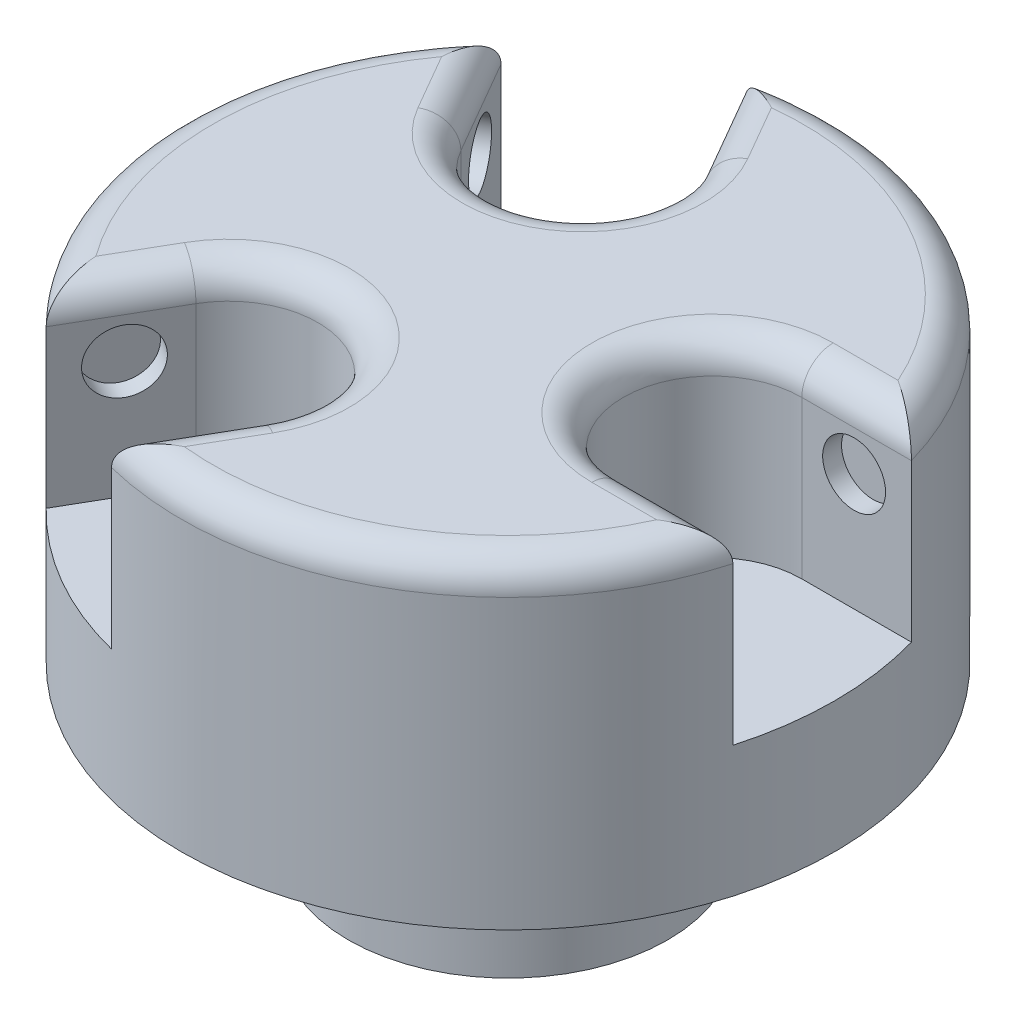
from build123d import *

# Parameters (mm, degrees)
SKETCH1_R                   = 51.94
BOSS_EXTRUDE1_DEPTH         = 50.8
CUT_EXTRUDE1_START          = -30
CUT_EXTRUDE1_DEPTH          = 120.309390324
SKETCH3_R                   = 5
CUT_EXTRUDE2_DEPTH          = 3
CIRPATTERN1_COUNT           = 3
CIRPATTERN1_COPY_1_SKETCH_R = 5
CIRPATTERN1_COPY_1_DEPTH    = 3
CIRPATTERN1_COPY_2_SKETCH_R = 5
CIRPATTERN1_COPY_2_DEPTH    = 3
FILLET2_R                   = 5
SKETCH6_R                   = 25.4
BOSS_EXTRUDE2_DEPTH         = 25.4


with BuildPart() as part:
    # Sketch1 → Boss-Extrude1 (new body)
    with BuildSketch(Plane(origin=(0, 0, 0), x_dir=(1, 0, 0), z_dir=(0, 1, 0))):
        Circle(SKETCH1_R)
    extrude(amount=BOSS_EXTRUDE1_DEPTH)

    # Sketch2 → Cut-Extrude1 (cut)
    with BuildSketch(Plane(origin=(0, 50.8, 0), x_dir=(1, 0, 0), z_dir=(0, 1, 0)).offset(CUT_EXTRUDE1_START)):
        with BuildLine():
            Line((302.928702249, 14.198513891), (49.96164332, 14.198513891))
            Line((49.96164332, 14.198513891), (32.527604999, 14.198513891))
            ThreePointArc((32.527604999, 14.198513891), (18.329091108, 0), (32.527604999, -14.198513891))
            Line((32.527604999, -14.198513891), (49.96164332, -14.198513891))
            Line((49.96164332, -14.198513891), (302.928702249, -14.198513891))
            Line((302.928702249, -14.198513891), (808.862820107, -14.198513891))
            Line((808.862820107, -14.198513891), (808.862820107, 14.198513891))
            Line((808.862820107, 14.198513891), (302.928702249, 14.198513891))
        make_face()
    cut_extrude1 = extrude(amount=CUT_EXTRUDE1_DEPTH, mode=Mode.SUBTRACT)

    # Sketch3 → Cut-Extrude2 (cut)
    with BuildSketch(Plane.XY.offset(-14.198513891)):
        with Locations((40.848803203, 39.398991639)):
            Circle(SKETCH3_R)
    cut_extrude2 = extrude(amount=-CUT_EXTRUDE2_DEPTH, mode=Mode.SUBTRACT)

    # Mirror1: Cut-Extrude2 across plane
    add(cut_extrude2.mirror(Plane.XY), mode=Mode.SUBTRACT)

    # CirPattern1: Cut-Extrude1, Cut-Extrude2 ×3 about axis
    cirpattern1_axis = Axis((0, 50.8, 0), (0, -1, 0))
    add([cut_extrude1.rotate(cirpattern1_axis, i * 360 / CIRPATTERN1_COUNT) for i in range(1, CIRPATTERN1_COUNT)], mode=Mode.SUBTRACT)
    add([cut_extrude2.rotate(cirpattern1_axis, i * 360 / CIRPATTERN1_COUNT) for i in range(1, CIRPATTERN1_COUNT)], mode=Mode.SUBTRACT)

    # CirPattern1 copy 1 sketch → CirPattern1 copy 1 (cut)
    with BuildSketch(Plane(origin=(-12.296273726, 0, -7.099256946), x_dir=(-0.4999999999999998, 0, 0.8660254037844387), z_dir=(0.8660254037844387, 0, 0.4999999999999998))):
        with Locations((40.848803203, -39.398991639)):
            Circle(CIRPATTERN1_COPY_1_SKETCH_R)
    extrude(amount=-CIRPATTERN1_COPY_1_DEPTH, mode=Mode.SUBTRACT)

    # CirPattern1 copy 2 sketch → CirPattern1 copy 2 (cut)
    with BuildSketch(Plane(origin=(12.296273726, 0, -7.099256946), x_dir=(-0.5000000000000004, 0, -0.8660254037844384), z_dir=(-0.8660254037844384, 0, 0.5000000000000004))):
        with Locations((40.848803203, -39.398991639)):
            Circle(CIRPATTERN1_COPY_2_SKETCH_R)
    extrude(amount=-CIRPATTERN1_COPY_2_DEPTH, mode=Mode.SUBTRACT)

    # Fillet2
    fillet2_edges = [part.edges().sort_by_distance(p)[0] for p in [
        (41.24462416, 50.8, -14.198513891),
        (18.329091108, 50.8, 0),
        (41.24462416, 50.8, 14.198513891),
        (25.97, 50.8, 44.981359473),
        (-8.326038354, 50.8, 42.818149238),
        (-9.164545554, 50.8, 15.873458528),
        (-32.918585806, 50.8, 28.619635346),
        (-51.94, 50.8, 0),
        (-32.918585806, 50.8, -28.619635346),
        (-9.164545554, 50.8, -15.873458528),
        (-8.326038354, 50.8, -42.818149238),
        (25.97, 50.8, -44.981359473),
    ]]
    fillet(fillet2_edges, radius=FILLET2_R)

    # Sketch6 → Boss-Extrude2 (add)
    with BuildSketch(Plane.XZ):
        Circle(SKETCH6_R)
    extrude(amount=BOSS_EXTRUDE2_DEPTH)


solid = part.part
